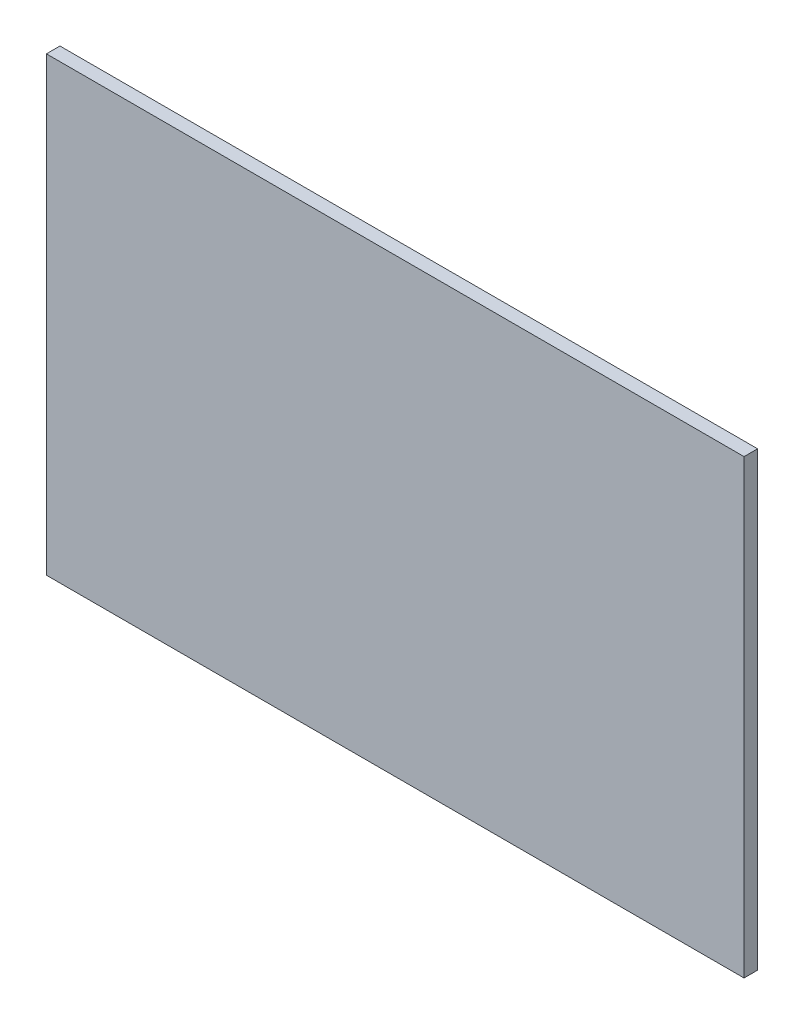
from build123d import *

# Parameters (mm, degrees)
ESQUISSE1_W        = 154.5
ESQUISSE1_H        = 100
BOSS_EXTRU_1_DEPTH = 3


with BuildPart() as part:
    # Esquisse1 → Boss.-Extru.1 (new body)
    with BuildSketch(Plane.XY):
        with Locations((-228.817496011, 158.30436223)):
            Rectangle(ESQUISSE1_W, ESQUISSE1_H)
    extrude(amount=BOSS_EXTRU_1_DEPTH)


solid = part.part
